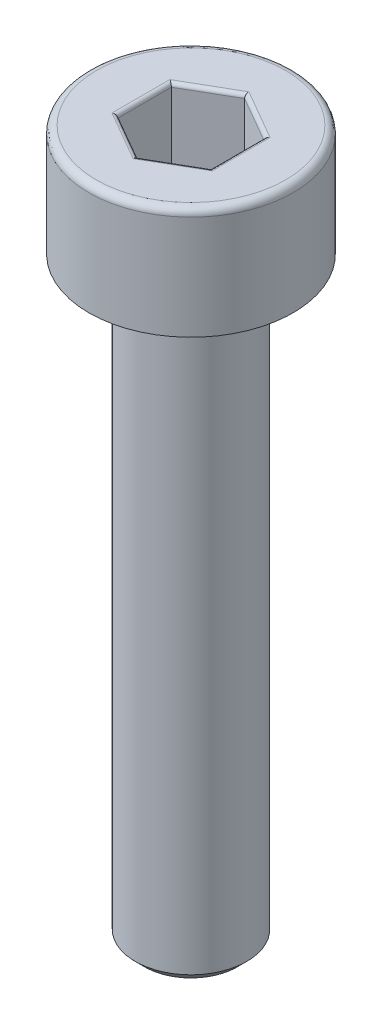
from build123d import *

# Parameters (mm, degrees)
CHAMFER1_SIZE      = 0.25
FILLET1_R          = 0.2
CUT_EXTRUDE1_DEPTH = 2
FILLET2_R          = 0.1


with BuildPart() as part:
    # Sketch1 → Revolve1 (revolve)
    with BuildSketch(Plane.XY):
        Polygon((0, -19), (-1.5, -19), (-1.5, -3), (-2.75, -3), (-2.75, 0), (0, 0), align=None)
    revolve(axis=Axis((0, 0, 0), (0, -1, 0)))

    # Chamfer1
    chamfer1_edges = [part.edges().sort_by_distance(p)[0] for p in [
        (1.5, -3, 0),
        (1.5, -19, 0),
    ]]
    chamfer(chamfer1_edges, length=CHAMFER1_SIZE)

    # Fillet1
    fillet1_edges = [part.edges().sort_by_distance(p)[0] for p in [
        (2.75, 0, 0),
    ]]
    fillet(fillet1_edges, radius=FILLET1_R)

    # Sketch2 → Cut-Extrude1 (cut)
    with BuildSketch(Plane(origin=(0, 0, 0), x_dir=(1, 0, 0), z_dir=(0, 1, 0))):
        Polygon((0, 1.443375673), (-1.25, 0.721687836), (-1.25, -0.721687836), (0, -1.443375673), (1.25, -0.721687836), (1.25, 0.721687836), align=None)
    extrude(amount=-CUT_EXTRUDE1_DEPTH, mode=Mode.SUBTRACT)

    # Fillet2
    fillet2_edges = [part.edges().sort_by_distance(p)[0] for p in [
        (0.625, -2, -1.082531755),
        (1.25, -2, 0),
        (0.625, -2, 1.082531755),
        (-0.625, -2, 1.082531755),
        (-1.25, -2, 0),
        (-0.625, -2, -1.082531755),
        (0.625, 0, -1.082531755),
        (-0.625, 0, -1.082531755),
        (-1.25, 0, 0),
        (-0.625, 0, 1.082531755),
        (0.625, 0, 1.082531755),
        (1.25, 0, 0),
    ]]
    fillet(fillet2_edges, radius=FILLET2_R)


solid = part.part
